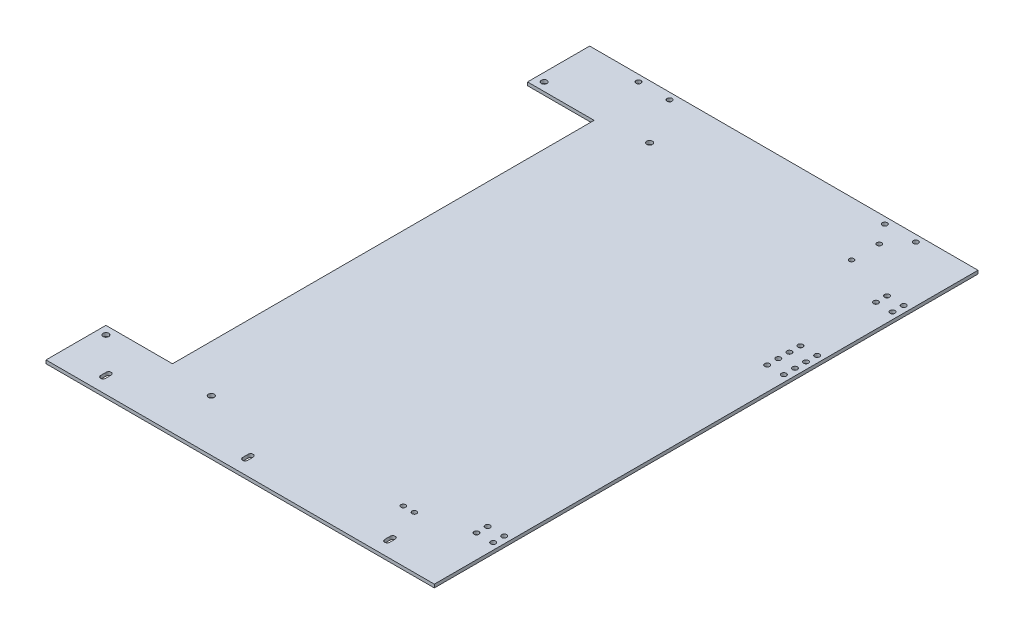
from build123d import *

# Parameters (mm, degrees)
SKETCH_1_W          = 350
SKETCH_1_H          = 3
EXTRUDE_1_DEPTH     = 490
SKETCH_2_R          = 2.6
SKETCH_2_R_2        = 2.25
SKETCH_2_R_3        = 2.1
SKETCH_2_W          = 60
SKETCH_2_H          = 380
CUT_EXTRUDE_1_DEPTH = 50


with BuildPart() as part:
    # 草图1 → 凸台-拉伸1 (new body)
    with BuildSketch(Plane.XY):
        with Locations((156.473684211, 4.735473664)):
            Rectangle(SKETCH_1_W, SKETCH_1_H)
    extrude(amount=EXTRUDE_1_DEPTH)

    # 草图2 → 切除-拉伸1 (cut)
    with BuildSketch(Plane(origin=(0, 6.235473664, 0), x_dir=(1, 0, 0), z_dir=(0, 1, 0))):
        with Locations((-11.026315789, -48.5)):
            Circle(SKETCH_2_R)
        with Locations((83.973684211, -48.5)):
            Circle(SKETCH_2_R)
        with Locations((-11.026315789, -443.5)):
            Circle(SKETCH_2_R)
        with Locations((83.973684211, -443.5)):
            Circle(SKETCH_2_R)
        with Locations((310.473684211, -159)):
            Circle(SKETCH_2_R_2)
        with Locations((325.473684211, -159)):
            Circle(SKETCH_2_R_2)
        with Locations((325.473684211, -169)):
            Circle(SKETCH_2_R_2)
        with Locations((310.473684211, -169)):
            Circle(SKETCH_2_R_2)
        with Locations((310.473684211, -431)):
            Circle(SKETCH_2_R_2)
        with Locations((325.473684211, -431)):
            Circle(SKETCH_2_R_2)
        with Locations((325.473684211, -421)):
            Circle(SKETCH_2_R_2)
        with Locations((310.473684211, -421)):
            Circle(SKETCH_2_R_2)
        with Locations((325.473684211, -149)):
            Circle(SKETCH_2_R_2)
        with Locations((310.473684211, -149)):
            Circle(SKETCH_2_R_2)
        with Locations((310.473684211, -139)):
            Circle(SKETCH_2_R_2)
        with Locations((325.473684211, -139)):
            Circle(SKETCH_2_R_2)
        with Locations((310.473684211, -71)):
            Circle(SKETCH_2_R_2)
        with Locations((310.473684211, -61)):
            Circle(SKETCH_2_R_2)
        with Locations((325.473684211, -61)):
            Circle(SKETCH_2_R_2)
        with Locations((325.473684211, -71)):
            Circle(SKETCH_2_R_2)
        with Locations((281.473684211, -6)):
            Circle(SKETCH_2_R_2)
        with Locations((253.473684211, -6)):
            Circle(SKETCH_2_R_2)
        with Locations((31.473684211, -6)):
            Circle(SKETCH_2_R_2)
        with Locations((59.473684211, -6)):
            Circle(SKETCH_2_R_2)
        with Locations((266.473684211, -24)):
            Circle(SKETCH_2_R_3)
        with Locations((266.473684211, -49)):
            Circle(SKETCH_2_R_3)
        with Locations((266.473684211, -443)):
            Circle(SKETCH_2_R_3)
        with Locations((256.473684211, -443)):
            Circle(SKETCH_2_R_3)
        with Locations((11.473684211, -246)):
            Rectangle(SKETCH_2_W, SKETCH_2_H)
        with BuildLine():
            Line((274.223684211, -472.5), (274.223684211, -477.5))
            ThreePointArc((274.223684211, -477.5), (276.473684211, -479.75), (278.723684211, -477.5))
            Line((278.723684211, -477.5), (278.723684211, -472.5))
            ThreePointArc((278.723684211, -472.5), (276.473684211, -470.25), (274.223684211, -472.5))
        make_face()
        with BuildLine():
            Line((146.223684211, -472.5), (146.223684211, -477.5))
            ThreePointArc((146.223684211, -477.5), (148.473684211, -479.75), (150.723684211, -477.5))
            Line((150.723684211, -477.5), (150.723684211, -472.5))
            ThreePointArc((150.723684211, -472.5), (148.473684211, -470.25), (146.223684211, -472.5))
        make_face()
        with BuildLine():
            Line((18.223684211, -472.5), (18.223684211, -477.5))
            ThreePointArc((18.223684211, -477.5), (20.473684211, -479.75), (22.723684211, -477.5))
            Line((22.723684211, -477.5), (22.723684211, -472.5))
            ThreePointArc((22.723684211, -472.5), (20.473684211, -470.25), (18.223684211, -472.5))
        make_face()
    extrude(amount=-CUT_EXTRUDE_1_DEPTH, mode=Mode.SUBTRACT)


solid = part.part
